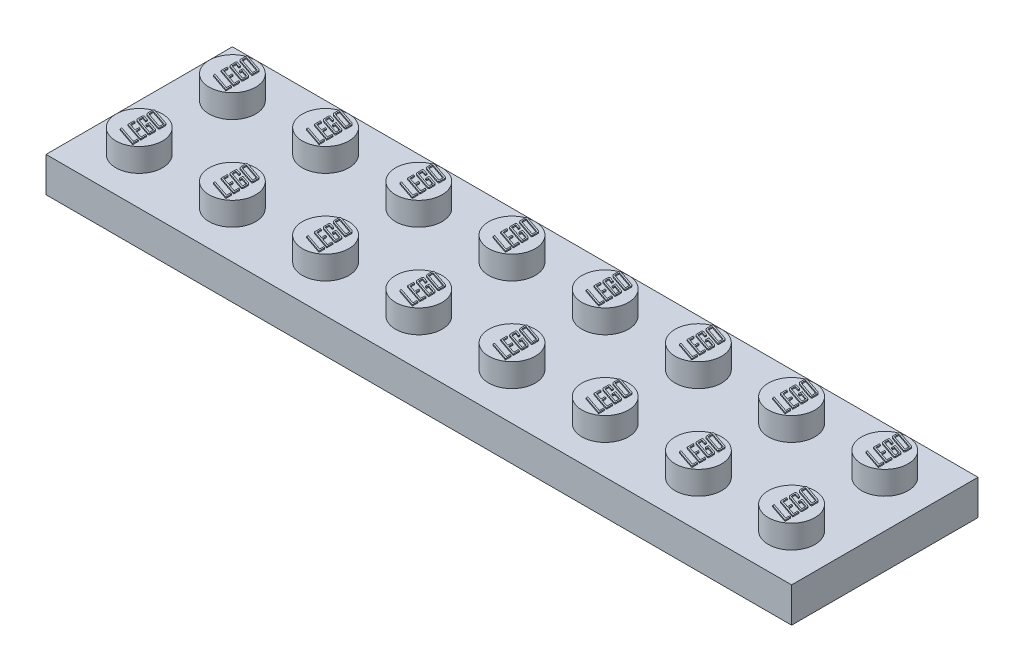
from build123d import *

# Parameters (mm, degrees)
SKETCH1_W            = 64
SKETCH1_H            = 16
BOSS_EXTRUDE1_DEPTH  = 3
SKETCH2_R            = 2
BOSS_EXTRUDE2_DEPTH  = 2
SHELL1_T             = -1
SKETCH3_R            = 2.8
SKETCH3_R_2          = 1.8
BOSS_EXTRUDE3_DEPTH  = 2
LPATTERN1_COUNT      = 7
LPATTERN1_PITCH      = 8
BOSS_EXTRUDE4_DEPTH  = 0.1
LPATTERN2_COUNT      = 8
LPATTERN2_PITCH      = 8
LPATTERN2_COUNT_DIR2 = 2
LPATTERN2_PITCH_DIR2 = 8


with BuildPart() as part:
    # Sketch1 → Boss-Extrude1 (new body)
    with BuildSketch(Plane(origin=(0, 0, 0), x_dir=(1, 0, 0), z_dir=(0, 1, 0))):
        Rectangle(SKETCH1_W, SKETCH1_H)
    extrude(amount=BOSS_EXTRUDE1_DEPTH)

    # Sketch2 → Boss-Extrude2 (add)
    with BuildSketch(Plane(origin=(0, 3, 0), x_dir=(1, 0, 0), z_dir=(0, 1, 0))):
        with Locations((-28, 4)):
            Circle(SKETCH2_R)
        with Locations((-20, 4)):
            Circle(SKETCH2_R)
        with Locations((-12, 4)):
            Circle(SKETCH2_R)
        with Locations((-4, 4)):
            Circle(SKETCH2_R)
        with Locations((4, 4)):
            Circle(SKETCH2_R)
        with Locations((12, 4)):
            Circle(SKETCH2_R)
        with Locations((20, 4)):
            Circle(SKETCH2_R)
        with Locations((28, 4)):
            Circle(SKETCH2_R)
        with Locations((-20, -4)):
            Circle(SKETCH2_R)
        with Locations((-12, -4)):
            Circle(SKETCH2_R)
        with Locations((-4, -4)):
            Circle(SKETCH2_R)
        with Locations((4, -4)):
            Circle(SKETCH2_R)
        with Locations((12, -4)):
            Circle(SKETCH2_R)
        with Locations((20, -4)):
            Circle(SKETCH2_R)
        with Locations((28, -4)):
            Circle(SKETCH2_R)
        with Locations((-28, -4)):
            Circle(SKETCH2_R)
    extrude(amount=BOSS_EXTRUDE2_DEPTH)

    # Shell1
    shell1_openings = [part.faces().sort_by_distance(p)[0] for p in [
        (0, 0, 0),
    ]]
    offset(amount=SHELL1_T, openings=shell1_openings, kind=Kind.INTERSECTION)

    # Sketch3 → Boss-Extrude3 (add)
    with BuildSketch(Plane.XZ.offset(-2)):
        with Locations((-24, 0)):
            Circle(SKETCH3_R)
        with Locations((-24, 0)):
            Circle(SKETCH3_R_2, mode=Mode.SUBTRACT)
    boss_extrude3 = extrude(amount=BOSS_EXTRUDE3_DEPTH)

    # LPattern1: Boss-Extrude3 ×7
    with Locations(*[(i * LPATTERN1_PITCH, 0, 0) for i in range(1, LPATTERN1_COUNT)]):
        add(boss_extrude3)

    # Sketch4 → Boss-Extrude4 (add)
    with BuildSketch(Plane(origin=(0, 5, 0), x_dir=(1, 0, 0), z_dir=(0, 1, 0))):
        Polygon((-27, -5.07639621), (-27, -5.563586671), (-28.617472331, -5.013974932), (-28.617472331, -4.877561603), (-27.116925711, -5.387284623), (-27.116925711, -5.036507491), align=None)
        Polygon((-27, -4.375816327), (-27, -4.901982025), (-28.617472331, -4.352370286), (-28.617472331, -3.826204588), (-28.50054662, -3.865788813), (-28.50054662, -4.255541182), (-27.896430448, -4.460770163), (-27.896430448, -4.109993032), (-27.779504738, -4.149881751), (-27.779504738, -4.500658882), (-27.116925711, -4.725679977), (-27.116925711, -4.335927608), align=None)
        with BuildLine():
            add(Edge.make_bspline(
                [(-27.119361663, -3.517813026), (-27.110800141, -3.521081683), (-27.093957071, -3.527512106), (-27.071136724, -3.542064932), (-27.050497165, -3.559372092), (-27.033052828, -3.580182774), (-27.018500741, -3.602746648), (-27.007534489, -3.626650767), (-27.001277974, -3.651879609), (-27.000429102, -3.669012008), (-27, -3.677672396)],
                knots=[0, 0, 0, 0, 2.7428e-05, 5.3959e-05, 8.0744e-05, 0.000107959, 0.000135072, 0.000161104, 0.000186509, 0.000212479, 0.000212479, 0.000212479, 0.000212479], degree=3))
            Line((-27, -3.677672396), (-27, -4.06255286))
            add(Edge.make_bspline(
                [(-27, -4.06255286), (-27.000393246, -4.070705946), (-27.001133583, -4.086055188), (-27.007020863, -4.107517184), (-27.018155678, -4.124889212), (-27.032963953, -4.138214779), (-27.051198157, -4.147092769), (-27.072180736, -4.150147032), (-27.095408139, -4.148459065), (-27.111004717, -4.143873728), (-27.119361663, -4.141416816)],
                knots=[0, 0, 0, 0, 2.4453e-05, 4.6035e-05, 6.5886e-05, 8.5509e-05, 0.000105119, 0.000125794, 0.000148378, 0.000174447, 0.000174447, 0.000174447, 0.000174447], degree=3))
            Line((-27.119361663, -4.141416816), (-28.498110668, -3.672800492))
            add(Edge.make_bspline(
                [(-28.498110668, -3.672800492), (-28.5066755, -3.669536063), (-28.523525082, -3.663113957), (-28.546242298, -3.648535645), (-28.567072315, -3.631470812), (-28.584695841, -3.610808853), (-28.59943062, -3.588179121), (-28.609796412, -3.56395811), (-28.616226976, -3.53874798), (-28.617054181, -3.521606234), (-28.617472331, -3.512941121)],
                knots=[0, 0, 0, 0, 2.7428e-05, 5.3959e-05, 8.0548e-05, 0.000107961, 0.000135075, 0.000161263, 0.000186668, 0.000212637, 0.000212637, 0.000212637, 0.000212637], degree=3))
            Line((-28.617472331, -3.512941121), (-28.617472331, -3.128060657))
            add(Edge.make_bspline(
                [(-28.617472331, -3.128060657), (-28.617089341, -3.119900586), (-28.616368314, -3.104538193), (-28.610367358, -3.083216169), (-28.599752475, -3.065643916), (-28.584628573, -3.052622347), (-28.566328347, -3.043968349), (-28.545330206, -3.040338163), (-28.522057661, -3.042193312), (-28.506465336, -3.046753347), (-28.498110668, -3.049196701)],
                knots=[0, 0, 0, 0, 2.4453e-05, 4.6035e-05, 6.5724e-05, 8.5145e-05, 0.00010503, 0.000125756, 0.00014834, 0.00017441, 0.00017441, 0.00017441, 0.00017441], degree=3))
            Line((-28.498110668, -3.049196701), (-28.13028187, -3.174039257))
            Line((-28.13028187, -3.174039257), (-28.13028187, -3.310452586))
            Line((-28.13028187, -3.310452586), (-28.50054662, -3.184696548))
            Line((-28.50054662, -3.184696548), (-28.50054662, -3.53547368))
            Line((-28.50054662, -3.53547368), (-27.116925711, -4.005612475))
            Line((-27.116925711, -4.005612475), (-27.116925711, -3.654835343))
            Line((-27.116925711, -3.654835343), (-27.701554264, -3.45630523))
            Line((-27.701554264, -3.45630523), (-27.701554264, -3.631693796))
            Line((-27.701554264, -3.631693796), (-27.818479975, -3.591805077))
            Line((-27.818479975, -3.591805077), (-27.818479975, -3.280003182))
            Line((-27.818479975, -3.280003182), (-27.119361663, -3.517813026))
        make_face()
        with BuildLine():
            add(Edge.make_bspline(
                [(-27.119361663, -2.622356959), (-27.110800151, -2.625625617), (-27.093957099, -2.632056045), (-27.071136615, -2.646608841), (-27.050497579, -2.663916116), (-27.033051257, -2.684726357), (-27.01850648, -2.707291854), (-27.007472842, -2.731280171), (-27.001338446, -2.756537274), (-27.00044595, -2.773660455), (-27, -2.782216329)],
                knots=[0, 0, 0, 0, 2.7428e-05, 5.3959e-05, 8.0744e-05, 0.000107959, 0.000135072, 0.000161104, 0.000186805, 0.000212471, 0.000212471, 0.000212471, 0.000212471], degree=3))
            Line((-27, -2.782216329), (-27, -3.20607203))
            add(Edge.make_bspline(
                [(-27, -3.20607203), (-27.000393246, -3.214225115), (-27.001133583, -3.229574358), (-27.007020863, -3.251036354), (-27.018155678, -3.268408381), (-27.032963953, -3.281733948), (-27.051198157, -3.290611938), (-27.072180736, -3.293666201), (-27.095408139, -3.291978234), (-27.111004717, -3.287392897), (-27.119361663, -3.284935986)],
                knots=[0, 0, 0, 0, 2.4453e-05, 4.6035e-05, 6.5886e-05, 8.5509e-05, 0.000105119, 0.000125794, 0.000148378, 0.000174447, 0.000174447, 0.000174447, 0.000174447], degree=3))
            Line((-27.119361663, -3.284935986), (-28.498110668, -2.816319661))
            add(Edge.make_bspline(
                [(-28.498110668, -2.816319661), (-28.5066755, -2.813055232), (-28.523525082, -2.806633127), (-28.546242298, -2.792054815), (-28.567072315, -2.774989982), (-28.584695841, -2.754328023), (-28.59943062, -2.731698291), (-28.609796412, -2.707477279), (-28.616226976, -2.682267149), (-28.617054181, -2.665125404), (-28.617472331, -2.656460291)],
                knots=[0, 0, 0, 0, 2.7428e-05, 5.3959e-05, 8.0548e-05, 0.000107961, 0.000135075, 0.000161263, 0.000186668, 0.000212637, 0.000212637, 0.000212637, 0.000212637], degree=3))
            Line((-28.617472331, -2.656460291), (-28.617472331, -2.23260459))
            add(Edge.make_bspline(
                [(-28.617472331, -2.23260459), (-28.617101546, -2.224442674), (-28.616407921, -2.209174255), (-28.610314395, -2.187965858), (-28.599661904, -2.170499732), (-28.584741376, -2.157137097), (-28.56631393, -2.148528669), (-28.545334491, -2.144877225), (-28.522056351, -2.146738734), (-28.506464879, -2.151297799), (-28.498110668, -2.153740634)],
                knots=[0, 0, 0, 0, 2.4453e-05, 4.5743e-05, 6.5432e-05, 8.5055e-05, 0.00010494, 0.000125666, 0.00014825, 0.000174319, 0.000174319, 0.000174319, 0.000174319], degree=3))
            Line((-28.498110668, -2.153740634), (-27.119361663, -2.622356959))
        make_face()
        Polygon((-27.116925711, -2.759379276), (-28.50054662, -2.289240481), (-28.50054662, -2.67899285), (-27.116925711, -3.149131645), align=None, mode=Mode.SUBTRACT)
    boss_extrude4 = extrude(amount=BOSS_EXTRUDE4_DEPTH)

    # LPattern2: Boss-Extrude4 8 × 2
    with Locations(*[(i * LPATTERN2_PITCH, 0, -j * LPATTERN2_PITCH_DIR2) for i in range(LPATTERN2_COUNT) for j in range(LPATTERN2_COUNT_DIR2) if (i, j) != (0, 0)]):
        add(boss_extrude4)


solid = part.part
